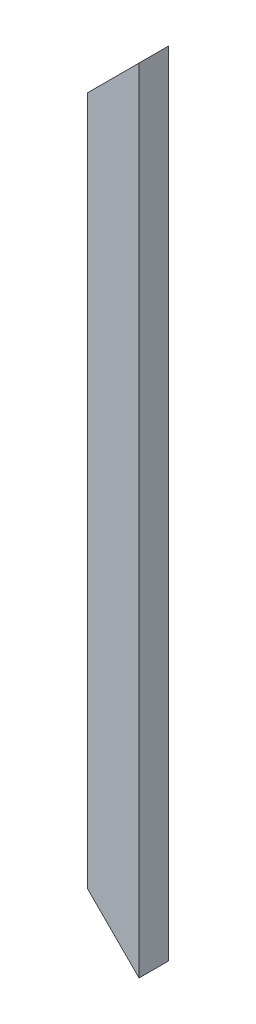
from build123d import *

# Parameters (mm, degrees)
SKETCH1_W           = 25.4
SKETCH1_H           = 682.499465201
BOSS_EXTRUDE1_DEPTH = 44.45
CUT_EXTRUDE1_DEPTH  = 44.45
CUT_EXTRUDE2_DEPTH  = 44.45


with BuildPart() as part:
    # Sketch1 → Boss-Extrude1 (new body)
    with BuildSketch(Plane(origin=(0, 0, 0), x_dir=(0, 0, -1), z_dir=(1, 0, 0))):
        with Locations((12.7, 341.249732601)):
            Rectangle(SKETCH1_W, SKETCH1_H)
    extrude(amount=BOSS_EXTRUDE1_DEPTH)

    # Sketch2 → Cut-Extrude1 (cut)
    with BuildSketch(Plane.XY):
        Polygon((44.45, 0), (0, 44.45), (0, 0), align=None)
    extrude(amount=-CUT_EXTRUDE1_DEPTH, mode=Mode.SUBTRACT)

    # Sketch3 → Cut-Extrude2 (cut)
    with BuildSketch(Plane.XY):
        Polygon((0, 638.049465201), (44.45, 682.499465201), (0, 682.499465201), align=None)
    extrude(amount=-CUT_EXTRUDE2_DEPTH, mode=Mode.SUBTRACT)


solid = part.part
